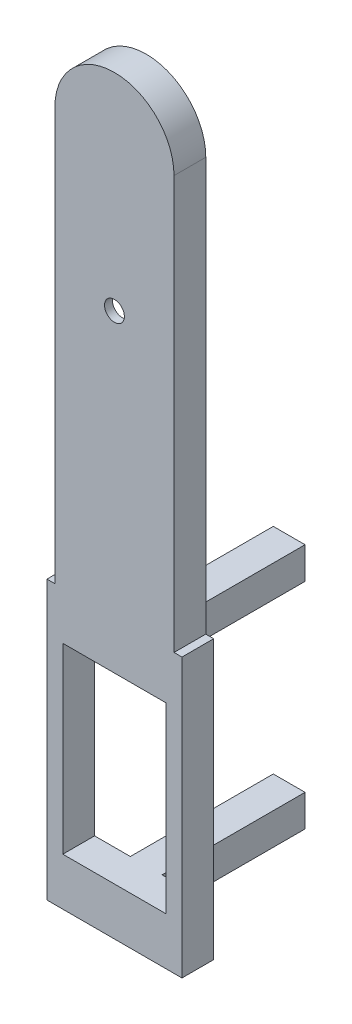
from build123d import *

# Parameters (mm, degrees)
EXTRUDE_1_DEPTH     = 4
CUT_EXTRUDE_1_DEPTH = 3
SKETCH_5_R          = 1.25
CUT_EXTRUDE_2_DEPTH = 12.4
SKETCH_6_W          = 17
SKETCH_6_H          = 35
EXTRUDE_2_DEPTH     = 4
SKETCH_7_W          = 13
SKETCH_7_H          = 23
CUT_EXTRUDE_3_DEPTH = 12.1
SKETCH_8_W          = 4
SKETCH_8_H          = 4
SKETCH_8_R          = 1.25
EXTRUDE_3_DEPTH     = 18


with BuildPart() as part:
    # 草圖1 → 填料-伸長1 (new body)
    with BuildSketch(Plane.XY):
        with BuildLine():
            Line((7.5, 0), (7.5, 52))
            ThreePointArc((7.5, 52), (0, 59.5), (-7.5, 52))
            Line((-7.5, 52), (-7.5, 0))
            Line((-7.5, 0), (7.5, 0))
        make_face()
    extrude(amount=EXTRUDE_1_DEPTH)

    # 草圖3 → 除料-伸長1 (cut)
    with BuildSketch(Plane.XY):
        with BuildLine():
            ThreePointArc((-2.5, 48.75876512), (0, 51.25876512), (2.5, 48.75876512))
            Line((2.5, 48.75876512), (5, 33.5))
            Line((5, 33.5), (2.467939071, 17.842139978))
            ThreePointArc((2.467939071, 17.842139978), (-0.200190311, 15.749263002), (-2.5, 18.24123488))
            Line((-2.5, 18.24123488), (-5, 33.5))
            Line((-5, 33.5), (-2.5, 48.75876512))
        make_face()
    extrude(amount=CUT_EXTRUDE_1_DEPTH, mode=Mode.SUBTRACT)

    # 草圖5 → 除料-伸長2 (cut)
    with BuildSketch(Plane.XY):
        with Locations((0, 33.5)):
            Circle(SKETCH_5_R)
    extrude(amount=CUT_EXTRUDE_2_DEPTH, mode=Mode.SUBTRACT)

    # 草圖6 → 填料-伸長2 (add)
    with BuildSketch(Plane.XY):
        with Locations((0, -17.5)):
            Rectangle(SKETCH_6_W, SKETCH_6_H)
    extrude(amount=EXTRUDE_2_DEPTH)

    # 草圖7 → 除料-伸長3 (cut)
    with BuildSketch(Plane.XY):
        with Locations((0, -17.5)):
            Rectangle(SKETCH_7_W, SKETCH_7_H)
    extrude(amount=CUT_EXTRUDE_3_DEPTH, mode=Mode.SUBTRACT)

    # 草圖8 → 填料-伸長3 (add)
    with BuildSketch(Plane.XY):
        with Locations((0, -4)):
            Rectangle(SKETCH_8_W, SKETCH_8_H)
        with Locations((0, -4)):
            Circle(SKETCH_8_R, mode=Mode.SUBTRACT)
        with Locations((0, -31)):
            Rectangle(SKETCH_8_W, SKETCH_8_H)
        with Locations((0, -31)):
            Circle(SKETCH_8_R, mode=Mode.SUBTRACT)
    extrude(amount=-EXTRUDE_3_DEPTH)


solid = part.part
